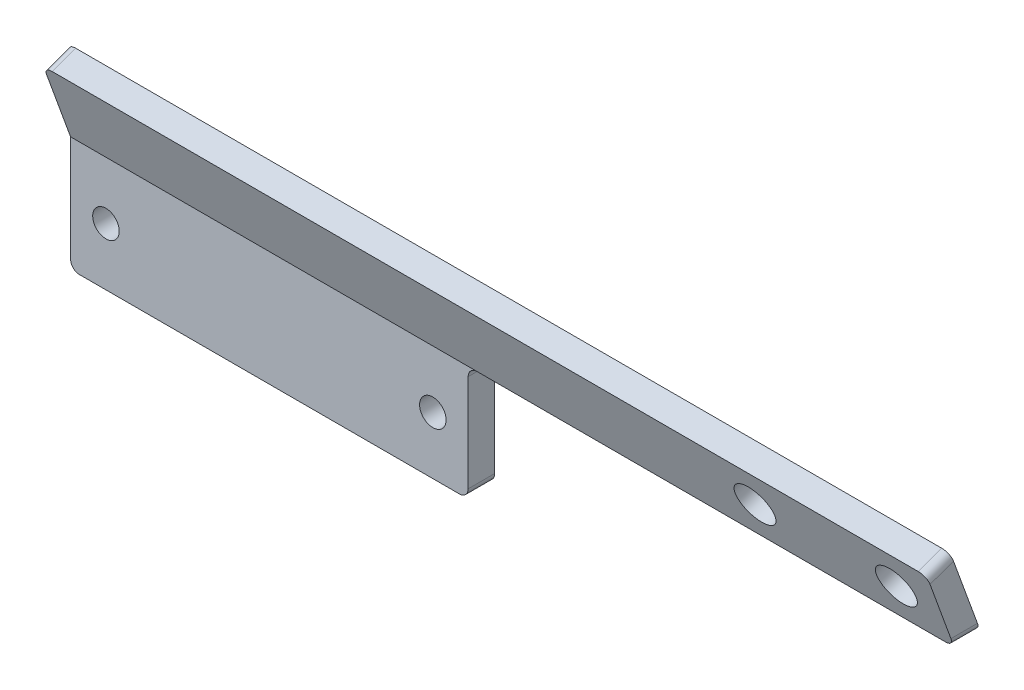
from build123d import *

# Parameters (mm, degrees)
ESQUISSE1_W                = 45
ESQUISSE1_H                = 13
BOSS_EXTRU_1_DEPTH         = 3
ESQUISSE2_R                = 1.5
ENL_V_MAT_EXTRU_1_DEPTH    = 47.936126811
BOSS_EXTRU_3_DEPTH         = 100
CONG_1_R                   = 1
ESQUISSE12_R               = 2.25
ENL_V_MAT_EXTRU_3_DEPTH    = 103.638868855
R_P_TITION_LIN_AIRE1_COUNT = 2
R_P_TITION_LIN_AIRE1_PITCH = 16


with BuildPart() as part:
    # Esquisse1 → Boss.-Extru.1 (new body)
    with BuildSketch(Plane.XY):
        with Locations((22.5, 6.5)):
            Rectangle(ESQUISSE1_W, ESQUISSE1_H)
    extrude(amount=BOSS_EXTRU_1_DEPTH)

    # Esquisse2 → Enlèv. mat.-Extru.1 (cut, through all)
    with BuildSketch(Plane.XY.offset(3)):
        with Locations((41, 6.5)):
            Circle(ESQUISSE2_R)
    enl_v_mat_extru_1 = extrude(amount=-ENL_V_MAT_EXTRU_1_DEPTH, mode=Mode.SUBTRACT)

    # Symétrie1: Enlèv. mat.-Extru.1 across plane
    add(enl_v_mat_extru_1.mirror(Plane.ZY.offset(-22.5)), mode=Mode.SUBTRACT)

    # Esquisse8 → Boss.-Extru.3 (add)
    with BuildSketch(Plane.ZY):
        Polygon((0, 13), (3.420201433, 22.396926208), (6.069268098, 21.432744793), (3, 13), align=None)
    extrude(amount=-BOSS_EXTRU_3_DEPTH)

    # Congé1
    cong_1_edges = [part.edges().sort_by_distance(p)[0] for p in [
        (45, 0, 1.5),
        (0, 0, 1.5),
        (45, 13, 1.5),
        (100, 13, 1.5),
        (100, 21.914835501, 4.744734766),
        (0, 21.914835501, 4.744734766),
    ]]
    fillet(cong_1_edges, radius=CONG_1_R)

    # Esquisse12 → Enlèv. mat.-Extru.3 (cut, through all)
    with BuildSketch(Plane(origin=(0, 0.556529705, -1.529052798), x_dir=(1, 0, 0), z_dir=(0, -0.34202014332566943, 0.9396926207859083))):
        with Locations((95, 17.7420645)):
            Circle(ESQUISSE12_R)
    enl_v_mat_extru_3 = extrude(amount=-ENL_V_MAT_EXTRU_3_DEPTH, mode=Mode.SUBTRACT)

    # Répétition linéaire1: Enlèv. mat.-Extru.3 ×2
    with Locations(*[(-i * R_P_TITION_LIN_AIRE1_PITCH, 0, 0) for i in range(1, R_P_TITION_LIN_AIRE1_COUNT)]):
        add(enl_v_mat_extru_3, mode=Mode.SUBTRACT)


solid = part.part
